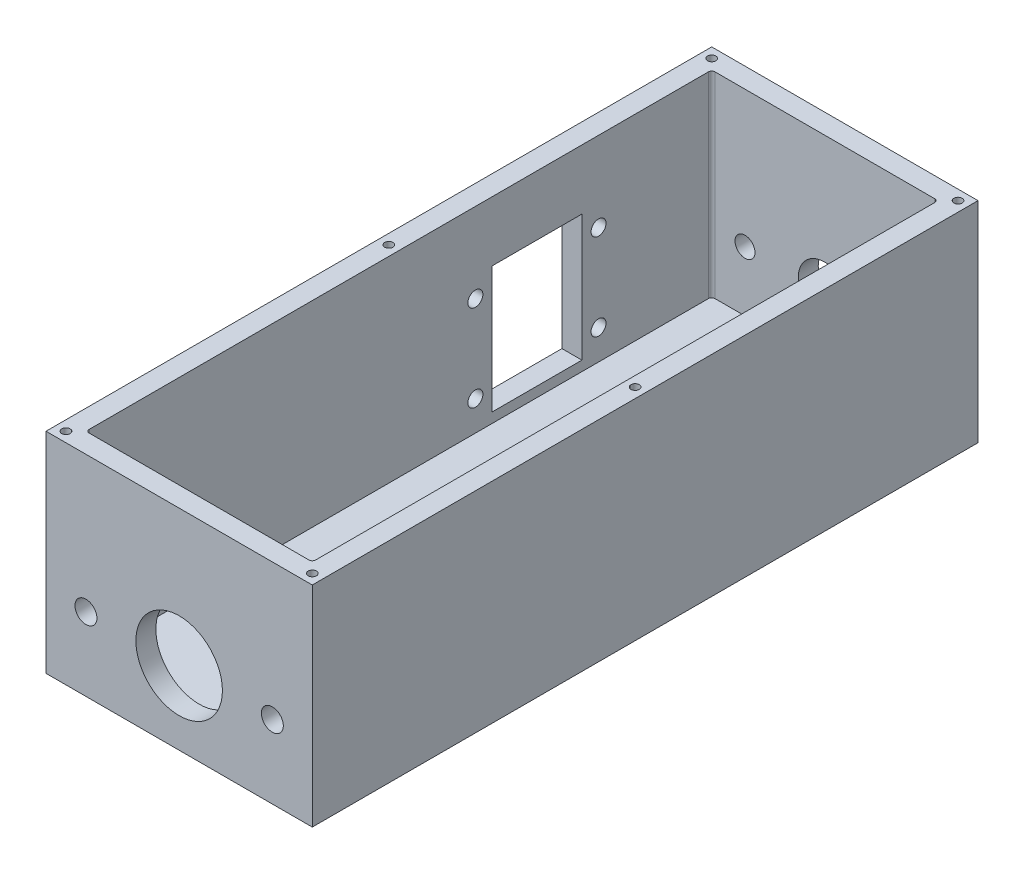
from build123d import *

# Parameters (mm, degrees)
SKETCH_1_W             = 80
SKETCH_1_H             = 48
EXTRUDE_1_DEPTH        = 200
CUT_EXTRUDE_1_DEPTH    = 44
SKETCH_3_R             = 3.3
SKETCH_3_R_2           = 13
CUT_EXTRUDE_2_DEPTH    = 10
SKETCH_4_R             = 2.25
SKETCH_4_W             = 27
SKETCH_4_H             = 38
CUT_EXTRUDE_3_DEPTH    = 10
SKETCH_5_R             = 8
SKETCH_5_R_2           = 3
CUT_EXTRUDE_4_DEPTH    = 10
SKETCH_6_R             = 3.500000002
SKETCH_6_R_2           = 3.5
CUT_EXTRUDE_5_DEPTH    = 10
SKETCH_8_W             = 80
SKETCH_8_H             = 200
EXTRUDE_2_DEPTH        = 15
HOLE_WIZARD_M3_1_D     = 2.5
HOLE_WIZARD_M3_1_DEPTH = 7.5
HOLE_WIZARD_M3_1_TIP   = 0.751075774


with BuildPart() as part:
    # 草图1 → 凸台-拉伸1 (new body)
    with BuildSketch(Plane.XY):
        Rectangle(SKETCH_1_W, SKETCH_1_H)
    extrude(amount=-EXTRUDE_1_DEPTH)

    # 草图2 → 切除-拉伸1 (cut)
    with BuildSketch(Plane(origin=(0, 24, 0), x_dir=(1, 0, 0), z_dir=(0, 1, 0))):
        with BuildLine():
            ThreePointArc((-34, 193), (-33.707106781, 193.707106781), (-33, 194))
            Line((-33, 194), (33, 194))
            ThreePointArc((33, 194), (33.707106781, 193.707106781), (34, 193))
            Line((34, 193), (34, 7))
            ThreePointArc((34, 7), (33.707106781, 6.292893219), (33, 6))
            Line((33, 6), (-33, 6))
            ThreePointArc((-33, 6), (-33.707106781, 6.292893219), (-34, 7))
            Line((-34, 7), (-34, 193))
        make_face()
    extrude(amount=-CUT_EXTRUDE_1_DEPTH, mode=Mode.SUBTRACT)

    # 草图3 → 切除-拉伸2 (cut)
    with BuildSketch(Plane.XY):
        with Locations((-28, -2)):
            Circle(SKETCH_3_R)
        with Locations((0, -2)):
            Circle(SKETCH_3_R_2)
        with Locations((28, -2)):
            Circle(SKETCH_3_R)
    extrude(amount=-CUT_EXTRUDE_2_DEPTH, mode=Mode.SUBTRACT)

    # 草图4 → 切除-拉伸3 (cut)
    with BuildSketch(Plane.ZY.offset(40)):
        with Locations((-123, -11)):
            Circle(SKETCH_4_R)
        with Locations((-123, 15)):
            Circle(SKETCH_4_R)
        with Locations((-160, 15)):
            Circle(SKETCH_4_R)
        with Locations((-160, -11)):
            Circle(SKETCH_4_R)
        with Locations((-141.5, 2)):
            Rectangle(SKETCH_4_W, SKETCH_4_H)
    extrude(amount=-CUT_EXTRUDE_3_DEPTH, mode=Mode.SUBTRACT)

    # 草图5 → 切除-拉伸4 (cut)
    with BuildSketch(Plane(origin=(0, 0, -200), x_dir=(-1, 0, 0), z_dir=(0, 0, -1))):
        with Locations((0, -2)):
            Circle(SKETCH_5_R)
        with Locations((24, -2)):
            Circle(SKETCH_5_R_2)
        with Locations((-24, -2)):
            Circle(SKETCH_5_R_2)
    extrude(amount=-CUT_EXTRUDE_4_DEPTH, mode=Mode.SUBTRACT)

    # 草图6 → 切除-拉伸5 (cut)
    with BuildSketch(Plane(origin=(0, -20, 0), x_dir=(1, 0, 0), z_dir=(0, 1, 0))):
        with Locations((-16, 168)):
            Circle(SKETCH_6_R)
        with Locations((-16, 115)):
            Circle(SKETCH_6_R_2)
    extrude(amount=-CUT_EXTRUDE_5_DEPTH, mode=Mode.SUBTRACT)

    # 草图8 → 凸台-拉伸2 (add)
    with BuildSketch(Plane(origin=(0, 24, 0), x_dir=(1, 0, 0), z_dir=(0, 1, 0))):
        with Locations((0, 100)):
            Rectangle(SKETCH_8_W, SKETCH_8_H)
        with BuildLine():
            Line((-33, 6), (33, 6))
            ThreePointArc((33, 6), (33.707106781, 6.292893219), (34, 7))
            Line((34, 7), (34, 193))
            ThreePointArc((34, 193), (33.707106781, 193.707106781), (33, 194))
            Line((33, 194), (-33, 194))
            ThreePointArc((-33, 194), (-33.707106781, 193.707106781), (-34, 193))
            Line((-34, 193), (-34, 7))
            ThreePointArc((-34, 7), (-33.707106781, 6.292893219), (-33, 6))
        make_face(mode=Mode.SUBTRACT)
    extrude(amount=EXTRUDE_2_DEPTH)

    # M3 螺纹孔1
    with Locations(Plane(origin=(-37, 39, -100), x_dir=(0, 0, 1), z_dir=(0, 1, 0))):
        with Locations((0, 0), (0, 74), (97, 74), (97, 0), (-97, 0), (-97, 74)):
            Hole(HOLE_WIZARD_M3_1_D / 2, depth=HOLE_WIZARD_M3_1_DEPTH)
            with Locations((0, 0, -(HOLE_WIZARD_M3_1_DEPTH + HOLE_WIZARD_M3_1_TIP / 2))):  # 118° drill point
                Cone(0, HOLE_WIZARD_M3_1_D / 2, HOLE_WIZARD_M3_1_TIP, mode=Mode.SUBTRACT)


solid = part.part
